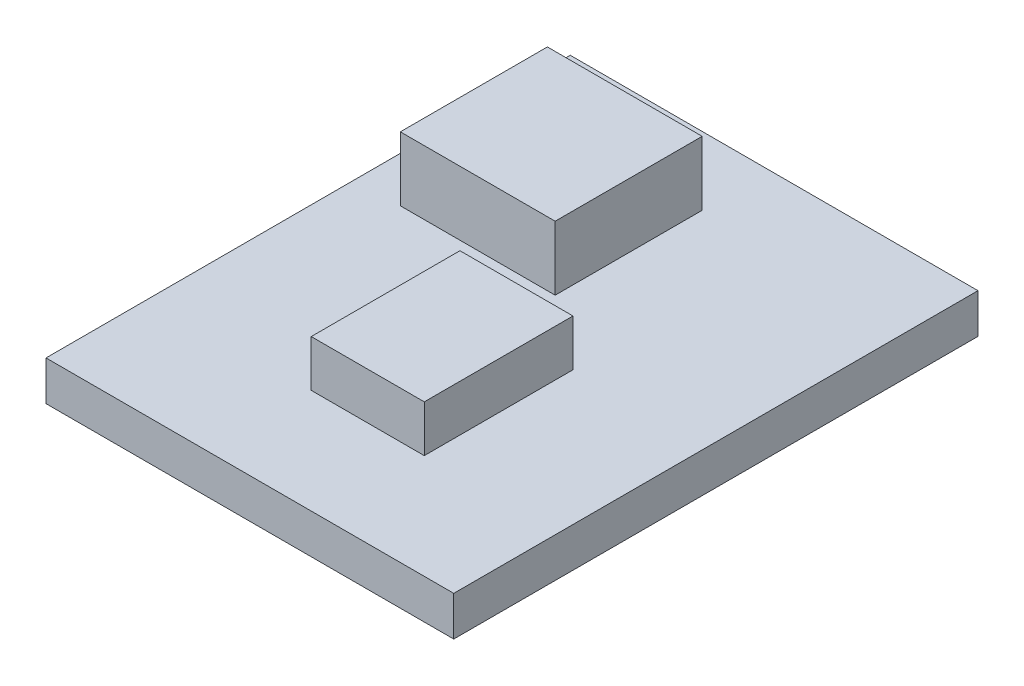
from build123d import *

# Parameters (mm, degrees)
SKETCH1_W           = 17.5
SKETCH1_H           = 22.5
BOSS_EXTRUDE1_DEPTH = 1.7
SKETCH2_W           = 6.644971707
SKETCH2_H           = 6.310332844
BOSS_EXTRUDE2_DEPTH = 2.75
SKETCH3_W           = 4.852263512
SKETCH3_H           = 6.382041172
BOSS_EXTRUDE3_DEPTH = 2


with BuildPart() as part:
    # Sketch1 → Boss-Extrude1 (new body)
    with BuildSketch(Plane(origin=(0, 0, 0), x_dir=(1, 0, 0), z_dir=(0, 1, 0))):
        with Locations((1.003989362, -11.25)):
            Rectangle(SKETCH1_W, SKETCH1_H)
    extrude(amount=BOSS_EXTRUDE1_DEPTH)

    # Sketch2 → Boss-Extrude2 (add)
    with BuildSketch(Plane(origin=(0, 1.7, 0), x_dir=(1, 0, 0), z_dir=(0, 1, 0))):
        with Locations((-2.473864536, -6.0870004)):
            Rectangle(SKETCH2_W, SKETCH2_H)
    extrude(amount=BOSS_EXTRUDE2_DEPTH)

    # Sketch3 → Boss-Extrude3 (add)
    with BuildSketch(Plane(origin=(0, 1.7, 0), x_dir=(1, 0, 0), z_dir=(0, 1, 0))):
        with Locations((1.577655984, -14.823465001)):
            Rectangle(SKETCH3_W, SKETCH3_H)
    extrude(amount=BOSS_EXTRUDE3_DEPTH)


solid = part.part
